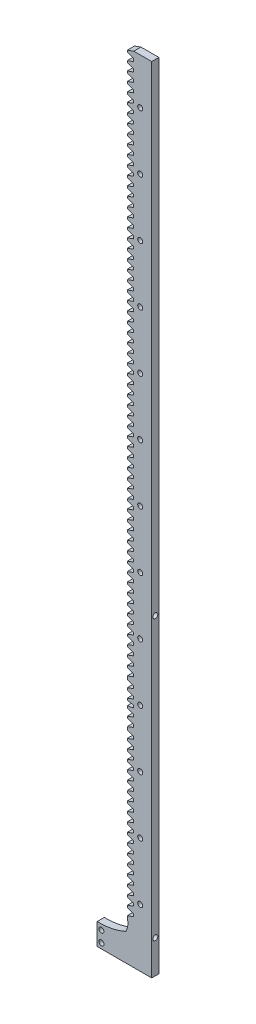
from build123d import *

# Parameters (mm, degrees)
EXTRUDE_1_DEPTH     = 5
SKETCH_2_R          = 1.75
CUT_EXTRUDE_1_DEPTH = 5
SKETCH_3_R          = 1.75
CUT_EXTRUDE_2_DEPTH = 10
SKETCH_4_R          = 1.75
CUT_EXTRUDE_3_DEPTH = 10


with BuildPart() as part:
    # 草图1 → 凸台-拉伸1 (new body)
    with BuildSketch(Plane.XY):
        with BuildLine():
            Line((0, 0), (-38, 0))
            Line((-38, 0), (-38, 15))
            ThreePointArc((-38, 15), (-27.771940478, 15.885441853), (-18.0028, 19.041563393))
            ThreePointArc((-18.0028, 19.041563393), (-16.669513035, 23.308519385), (-17, 27.766696808))
            Line((-17, 27.766696808), (-17, 29.050408521))
            Line((-17, 29.050408521), (-12.5, 30.688274575))
            Line((-12.5, 30.688274575), (-12.5, 32.412016054))
            Line((-12.5, 32.412016054), (-17, 34.049882108))
            Line((-17, 34.049882108), (-17, 35.333593821))
            Line((-17, 35.333593821), (-12.5, 36.971459875))
            Line((-12.5, 36.971459875), (-12.5, 38.695201354))
            Line((-12.5, 38.695201354), (-17, 40.333067408))
            Line((-17, 40.333067408), (-17, 41.616779121))
            Line((-17, 41.616779121), (-12.5, 43.254645175))
            Line((-12.5, 43.254645175), (-12.5, 44.978386654))
            Line((-12.5, 44.978386654), (-17, 46.616252708))
            Line((-17, 46.616252708), (-17, 47.899964421))
            Line((-17, 47.899964421), (-12.5, 49.537830475))
            Line((-12.5, 49.537830475), (-12.5, 51.261571954))
            Line((-12.5, 51.261571954), (-17, 52.899438008))
            Line((-17, 52.899438008), (-17, 54.183149721))
            Line((-17, 54.183149721), (-12.5, 55.821015775))
            Line((-12.5, 55.821015775), (-12.5, 57.544757254))
            Line((-12.5, 57.544757254), (-17, 59.182623308))
            Line((-17, 59.182623308), (-17, 60.466335021))
            Line((-17, 60.466335021), (-12.5, 62.104201075))
            Line((-12.5, 62.104201075), (-12.5, 63.827942554))
            Line((-12.5, 63.827942554), (-17, 65.465808608))
            Line((-17, 65.465808608), (-17, 66.749520321))
            Line((-17, 66.749520321), (-12.5, 68.387386375))
            Line((-12.5, 68.387386375), (-12.5, 70.111127854))
            Line((-12.5, 70.111127854), (-17, 71.748993908))
            Line((-17, 71.748993908), (-17, 73.032705621))
            Line((-17, 73.032705621), (-12.5, 74.670571675))
            Line((-12.5, 74.670571675), (-12.5, 76.394313154))
            Line((-12.5, 76.394313154), (-17, 78.032179208))
            Line((-17, 78.032179208), (-17, 79.315890921))
            Line((-17, 79.315890921), (-12.5, 80.953756975))
            Line((-12.5, 80.953756975), (-12.5, 82.677498454))
            Line((-12.5, 82.677498454), (-17, 84.315364508))
            Line((-17, 84.315364508), (-17, 85.599076221))
            Line((-17, 85.599076221), (-12.5, 87.236942275))
            Line((-12.5, 87.236942275), (-12.5, 88.960683754))
            Line((-12.5, 88.960683754), (-17, 90.598549808))
            Line((-17, 90.598549808), (-17, 91.882261521))
            Line((-17, 91.882261521), (-12.5, 93.520127575))
            Line((-12.5, 93.520127575), (-12.5, 95.243869054))
            Line((-12.5, 95.243869054), (-17, 96.881735108))
            Line((-17, 96.881735108), (-17, 98.165446821))
            Line((-17, 98.165446821), (-12.5, 99.803312875))
            Line((-12.5, 99.803312875), (-12.5, 101.527054354))
            Line((-12.5, 101.527054354), (-17, 103.164920408))
            Line((-17, 103.164920408), (-17, 104.448632121))
            Line((-17, 104.448632121), (-12.5, 106.086498175))
            Line((-12.5, 106.086498175), (-12.5, 107.810239654))
            Line((-12.5, 107.810239654), (-17, 109.448105708))
            Line((-17, 109.448105708), (-17, 110.731817421))
            Line((-17, 110.731817421), (-12.5, 112.369683475))
            Line((-12.5, 112.369683475), (-12.5, 114.093424954))
            Line((-12.5, 114.093424954), (-17, 115.731291008))
            Line((-17, 115.731291008), (-17, 117.015002721))
            Line((-17, 117.015002721), (-12.5, 118.652868775))
            Line((-12.5, 118.652868775), (-12.5, 120.376610254))
            Line((-12.5, 120.376610254), (-17, 122.014476308))
            Line((-17, 122.014476308), (-17, 123.298188021))
            Line((-17, 123.298188021), (-12.5, 124.936054075))
            Line((-12.5, 124.936054075), (-12.5, 126.659795554))
            Line((-12.5, 126.659795554), (-17, 128.297661608))
            Line((-17, 128.297661608), (-17, 129.581373321))
            Line((-17, 129.581373321), (-12.5, 131.219239375))
            Line((-12.5, 131.219239375), (-12.5, 132.942980854))
            Line((-12.5, 132.942980854), (-17, 134.580846908))
            Line((-17, 134.580846908), (-17, 135.864558621))
            Line((-17, 135.864558621), (-12.5, 137.502424675))
            Line((-12.5, 137.502424675), (-12.5, 139.226166154))
            Line((-12.5, 139.226166154), (-17, 140.864032208))
            Line((-17, 140.864032208), (-17, 143.007743921))
            Line((-17, 143.007743921), (-12.5, 144.645609975))
            Line((-12.5, 144.645609975), (-12.5, 146.369351454))
            Line((-12.5, 146.369351454), (-17, 148.007217508))
            Line((-17, 148.007217508), (-17, 149.290929221))
            Line((-17, 149.290929221), (-12.5, 150.928795275))
            Line((-12.5, 150.928795275), (-12.5, 152.652536754))
            Line((-12.5, 152.652536754), (-17, 154.290402808))
            Line((-17, 154.290402808), (-17, 155.574114521))
            Line((-17, 155.574114521), (-12.5, 156.351980575))
            Line((-12.5, 156.351980575), (-12.5, 158.071980575))
            Line((-12.5, 158.071980575), (-17, 158.84984663))
            Line((-17, 158.84984663), (-17, 160.133558343))
            Line((-17, 160.133558343), (-12.5, 161.771424397))
            Line((-12.5, 161.771424397), (-12.5, 163.495165875))
            Line((-12.5, 163.495165875), (-17, 165.13303193))
            Line((-17, 165.13303193), (-17, 166.416743643))
            Line((-17, 166.416743643), (-12.5, 168.054609697))
            Line((-12.5, 168.054609697), (-12.5, 169.778351175))
            Line((-12.5, 169.778351175), (-17, 171.41621723))
            Line((-17, 171.41621723), (-17, 173.559928943))
            Line((-17, 173.559928943), (-12.5, 175.197794997))
            Line((-12.5, 175.197794997), (-12.5, 176.921536475))
            Line((-12.5, 176.921536475), (-17, 178.55940253))
            Line((-17, 178.55940253), (-17, 179.843114243))
            Line((-17, 179.843114243), (-12.5, 181.480980297))
            Line((-12.5, 181.480980297), (-12.5, 183.204721775))
            Line((-12.5, 183.204721775), (-17, 184.84258783))
            Line((-17, 184.84258783), (-17, 186.126299543))
            Line((-17, 186.126299543), (-12.5, 187.764165597))
            Line((-12.5, 187.764165597), (-12.5, 189.487907075))
            Line((-12.5, 189.487907075), (-17, 191.12577313))
            Line((-17, 191.12577313), (-17, 192.409484843))
            Line((-17, 192.409484843), (-12.5, 194.047350897))
            Line((-12.5, 194.047350897), (-12.5, 195.771092375))
            Line((-12.5, 195.771092375), (-17, 197.40895843))
            Line((-17, 197.40895843), (-17, 198.692670143))
            Line((-17, 198.692670143), (-12.5, 200.330536197))
            Line((-12.5, 200.330536197), (-12.5, 202.054277675))
            Line((-12.5, 202.054277675), (-17, 203.69214373))
            Line((-17, 203.69214373), (-17, 204.975855443))
            Line((-17, 204.975855443), (-12.5, 206.613721497))
            Line((-12.5, 206.613721497), (-12.5, 208.337462975))
            Line((-12.5, 208.337462975), (-17, 209.97532903))
            Line((-17, 209.97532903), (-17, 211.259040743))
            Line((-17, 211.259040743), (-12.5, 212.896906797))
            Line((-12.5, 212.896906797), (-12.5, 214.620648275))
            Line((-12.5, 214.620648275), (-17, 216.25851433))
            Line((-17, 216.25851433), (-17, 217.542226043))
            Line((-17, 217.542226043), (-12.5, 219.180092097))
            Line((-12.5, 219.180092097), (-12.5, 220.903833575))
            Line((-12.5, 220.903833575), (-17, 222.54169963))
            Line((-17, 222.54169963), (-17, 223.825411343))
            Line((-17, 223.825411343), (-12.5, 225.463277397))
            Line((-12.5, 225.463277397), (-12.5, 227.187018875))
            Line((-12.5, 227.187018875), (-17, 228.82488493))
            Line((-17, 228.82488493), (-17, 230.108596643))
            Line((-17, 230.108596643), (-12.5, 231.746462697))
            Line((-12.5, 231.746462697), (-12.5, 233.470204175))
            Line((-12.5, 233.470204175), (-17, 235.10807023))
            Line((-17, 235.10807023), (-17, 236.391781943))
            Line((-17, 236.391781943), (-12.5, 238.029647997))
            Line((-12.5, 238.029647997), (-12.5, 239.753389475))
            Line((-12.5, 239.753389475), (-17, 241.39125553))
            Line((-17, 241.39125553), (-17, 242.674967243))
            Line((-17, 242.674967243), (-12.5, 244.312833297))
            Line((-12.5, 244.312833297), (-12.5, 246.036574775))
            Line((-12.5, 246.036574775), (-17, 247.67444083))
            Line((-17, 247.67444083), (-17, 248.958152543))
            Line((-17, 248.958152543), (-12.5, 250.596018597))
            Line((-12.5, 250.596018597), (-12.5, 252.319760075))
            Line((-12.5, 252.319760075), (-17, 253.95762613))
            Line((-17, 253.95762613), (-17, 255.241337843))
            Line((-17, 255.241337843), (-12.5, 256.879203897))
            Line((-12.5, 256.879203897), (-12.5, 258.602945375))
            Line((-12.5, 258.602945375), (-17, 260.24081143))
            Line((-17, 260.24081143), (-17, 261.524523143))
            Line((-17, 261.524523143), (-12.5, 263.162389197))
            Line((-12.5, 263.162389197), (-12.5, 264.886130675))
            Line((-12.5, 264.886130675), (-17, 266.52399673))
            Line((-17, 266.52399673), (-17, 267.807708443))
            Line((-17, 267.807708443), (-12.5, 269.445574497))
            Line((-12.5, 269.445574497), (-12.5, 271.169315975))
            Line((-12.5, 271.169315975), (-17, 272.80718203))
            Line((-17, 272.80718203), (-17, 274.090893743))
            Line((-17, 274.090893743), (-12.5, 275.728759797))
            Line((-12.5, 275.728759797), (-12.5, 277.452501275))
            Line((-12.5, 277.452501275), (-17, 279.09036733))
            Line((-17, 279.09036733), (-17, 280.374079043))
            Line((-17, 280.374079043), (-12.5, 282.011945097))
            Line((-12.5, 282.011945097), (-12.5, 283.735686575))
            Line((-12.5, 283.735686575), (-17, 285.37355263))
            Line((-17, 285.37355263), (-17, 286.657264343))
            Line((-17, 286.657264343), (-12.5, 288.295130397))
            Line((-12.5, 288.295130397), (-12.5, 290.018871875))
            Line((-12.5, 290.018871875), (-17, 291.65673793))
            Line((-17, 291.65673793), (-17, 292.940449643))
            Line((-17, 292.940449643), (-12.5, 294.578315697))
            Line((-12.5, 294.578315697), (-12.5, 296.302057175))
            Line((-12.5, 296.302057175), (-17, 297.93992323))
            Line((-17, 297.93992323), (-17, 299.223634943))
            Line((-17, 299.223634943), (-12.5, 300.861500997))
            Line((-12.5, 300.861500997), (-12.5, 301.721500997))
            Line((-12.5, 301.721500997), (-12.5, 302.581500997))
            Line((-12.5, 302.581500997), (-17, 304.219367051))
            Line((-17, 304.219367051), (-17, 305.503078764))
            Line((-17, 305.503078764), (-12.5, 307.140944818))
            Line((-12.5, 307.140944818), (-12.5, 308.864686297))
            Line((-12.5, 308.864686297), (-17, 310.502552351))
            Line((-17, 310.502552351), (-17, 311.786264064))
            Line((-17, 311.786264064), (-12.5, 313.424130118))
            Line((-12.5, 313.424130118), (-12.5, 315.147871597))
            Line((-12.5, 315.147871597), (-17, 316.785737651))
            Line((-17, 316.785737651), (-17, 318.069449364))
            Line((-17, 318.069449364), (-12.5, 319.707315418))
            Line((-12.5, 319.707315418), (-12.5, 321.431056897))
            Line((-12.5, 321.431056897), (-17, 323.068922951))
            Line((-17, 323.068922951), (-17, 324.352634664))
            Line((-17, 324.352634664), (-12.5, 325.990500718))
            Line((-12.5, 325.990500718), (-12.5, 327.714242197))
            Line((-12.5, 327.714242197), (-17, 329.352108251))
            Line((-17, 329.352108251), (-17, 330.635819964))
            Line((-17, 330.635819964), (-12.5, 332.273686018))
            Line((-12.5, 332.273686018), (-12.5, 333.993686018))
            Line((-12.5, 333.993686018), (-17, 335.631552072))
            Line((-17, 335.631552072), (-17, 336.915263785))
            Line((-17, 336.915263785), (-12.5, 338.553129839))
            Line((-12.5, 338.553129839), (-12.5, 340.273129839))
            Line((-12.5, 340.273129839), (-17, 341.910995894))
            Line((-17, 341.910995894), (-17, 343.194707607))
            Line((-17, 343.194707607), (-12.5, 344.832573661))
            Line((-12.5, 344.832573661), (-12.5, 346.552573661))
            Line((-12.5, 346.552573661), (-17, 348.190439715))
            Line((-17, 348.190439715), (-17, 349.474151428))
            Line((-17, 349.474151428), (-12.5, 351.112017482))
            Line((-12.5, 351.112017482), (-12.5, 352.835758961))
            Line((-12.5, 352.835758961), (-17, 354.473625015))
            Line((-17, 354.473625015), (-17, 355.757336728))
            Line((-17, 355.757336728), (-12.5, 357.395202782))
            Line((-12.5, 357.395202782), (-12.5, 359.118944261))
            Line((-12.5, 359.118944261), (-17, 360.756810315))
            Line((-17, 360.756810315), (-17, 362.040522028))
            Line((-17, 362.040522028), (-12.5, 363.678388082))
            Line((-12.5, 363.678388082), (-12.5, 365.402129561))
            Line((-12.5, 365.402129561), (-17, 367.039995615))
            Line((-17, 367.039995615), (-17, 368.323707328))
            Line((-17, 368.323707328), (-12.5, 369.961573382))
            Line((-12.5, 369.961573382), (-12.5, 371.685314861))
            Line((-12.5, 371.685314861), (-17, 373.323180915))
            Line((-17, 373.323180915), (-17, 374.606892628))
            Line((-17, 374.606892628), (-12.5, 376.244758682))
            Line((-12.5, 376.244758682), (-12.5, 377.104758682))
            Line((-12.5, 377.104758682), (-12.5, 377.964758682))
            Line((-12.5, 377.964758682), (-17, 379.602624736))
            Line((-17, 379.602624736), (-17, 380.886336449))
            Line((-17, 380.886336449), (-12.5, 382.524202503))
            Line((-12.5, 382.524202503), (-12.5, 384.247943982))
            Line((-12.5, 384.247943982), (-17, 385.885810036))
            Line((-17, 385.885810036), (-17, 387.169521749))
            Line((-17, 387.169521749), (-12.5, 388.807387803))
            Line((-12.5, 388.807387803), (-12.5, 390.531129282))
            Line((-12.5, 390.531129282), (-17, 392.168995336))
            Line((-17, 392.168995336), (-17, 393.452707049))
            Line((-17, 393.452707049), (-12.5, 395.090573103))
            Line((-12.5, 395.090573103), (-12.5, 396.814314582))
            Line((-12.5, 396.814314582), (-17, 398.452180636))
            Line((-17, 398.452180636), (-17, 399.735892349))
            Line((-17, 399.735892349), (-12.5, 401.373758403))
            Line((-12.5, 401.373758403), (-12.5, 403.097499882))
            Line((-12.5, 403.097499882), (-17, 404.735365936))
            Line((-17, 404.735365936), (-17, 406.019077649))
            Line((-17, 406.019077649), (-12.5, 407.656943703))
            Line((-12.5, 407.656943703), (-12.5, 409.376943703))
            Line((-12.5, 409.376943703), (-17, 411.014809758))
            Line((-17, 411.014809758), (-17, 412.298521471))
            Line((-17, 412.298521471), (-12.5, 413.936387525))
            Line((-12.5, 413.936387525), (-12.5, 415.660129003))
            Line((-12.5, 415.660129003), (-17, 417.297995058))
            Line((-17, 417.297995058), (-17, 418.581706771))
            Line((-17, 418.581706771), (-12.5, 420.219572825))
            Line((-12.5, 420.219572825), (-12.5, 421.943314303))
            Line((-12.5, 421.943314303), (-17, 423.581180358))
            Line((-17, 423.581180358), (-17, 424.864892071))
            Line((-17, 424.864892071), (-12.5, 426.502758125))
            Line((-12.5, 426.502758125), (-12.5, 428.226499603))
            Line((-12.5, 428.226499603), (-17, 429.864365658))
            Line((-17, 429.864365658), (-17, 431.148077371))
            Line((-17, 431.148077371), (-12.5, 432.785943425))
            Line((-12.5, 432.785943425), (-12.5, 434.509684903))
            Line((-12.5, 434.509684903), (-17, 436.147550958))
            Line((-17, 436.147550958), (-17, 437.431262671))
            Line((-17, 437.431262671), (-12.5, 439.069128725))
            Line((-12.5, 439.069128725), (-12.5, 439.929128725))
            Line((-12.5, 439.929128725), (-12.5, 440.789128725))
            Line((-12.5, 440.789128725), (-17, 442.426994779))
            Line((-17, 442.426994779), (-17, 443.710706492))
            Line((-17, 443.710706492), (-12.5, 445.348572546))
            Line((-12.5, 445.348572546), (-12.5, 447.072314025))
            Line((-12.5, 447.072314025), (-17, 448.710180079))
            Line((-17, 448.710180079), (-17, 449.993891792))
            Line((-17, 449.993891792), (-12.5, 451.631757846))
            Line((-12.5, 451.631757846), (-12.5, 453.355499325))
            Line((-12.5, 453.355499325), (-17, 454.993365379))
            Line((-17, 454.993365379), (-17, 456.277077092))
            Line((-17, 456.277077092), (-12.5, 457.914943146))
            Line((-12.5, 457.914943146), (-12.5, 459.638684625))
            Line((-12.5, 459.638684625), (-17, 461.276550679))
            Line((-17, 461.276550679), (-17, 462.560262392))
            Line((-17, 462.560262392), (-12.5, 464.198128446))
            Line((-12.5, 464.198128446), (-12.5, 465.058128446))
            Line((-12.5, 465.058128446), (-12.5, 465.918128446))
            Line((-12.5, 465.918128446), (-17, 467.5559945))
            Line((-17, 467.5559945), (-17, 468.839706213))
            Line((-17, 468.839706213), (-12.5, 470.477572267))
            Line((-12.5, 470.477572267), (-12.5, 472.201313746))
            Line((-12.5, 472.201313746), (-17, 473.8391798))
            Line((-17, 473.8391798), (-17, 475.122891513))
            Line((-17, 475.122891513), (-12.5, 476.760757567))
            Line((-12.5, 476.760757567), (-12.5, 478.484499046))
            Line((-12.5, 478.484499046), (-17, 480.1223651))
            Line((-17, 480.1223651), (-17, 481.406076813))
            Line((-17, 481.406076813), (-12.5, 483.043942867))
            Line((-12.5, 483.043942867), (-12.5, 484.767684346))
            Line((-12.5, 484.767684346), (-17, 486.4055504))
            Line((-17, 486.4055504), (-17, 487.689262113))
            Line((-17, 487.689262113), (-12.5, 489.327128167))
            Line((-12.5, 489.327128167), (-12.5, 491.050869646))
            Line((-12.5, 491.050869646), (-17, 492.6887357))
            Line((-17, 492.6887357), (-17, 493.972447413))
            Line((-17, 493.972447413), (-12.5, 495.610313467))
            Line((-12.5, 495.610313467), (-12.5, 497.334054946))
            Line((-12.5, 497.334054946), (-17, 498.971921))
            Line((-17, 498.971921), (-17, 500.255632713))
            Line((-17, 500.255632713), (-12.5, 501.893498767))
            Line((-12.5, 501.893498767), (-12.5, 502.753498767))
            Line((-12.5, 502.753498767), (-12.5, 503.613498767))
            Line((-12.5, 503.613498767), (-17, 505.251364822))
            Line((-17, 505.251364822), (-17, 506.535076535))
            Line((-17, 506.535076535), (-12.5, 508.172942589))
            Line((-12.5, 508.172942589), (-12.5, 509.896684067))
            Line((-12.5, 509.896684067), (-17, 511.534550122))
            Line((-17, 511.534550122), (-17, 512.818261835))
            Line((-17, 512.818261835), (-12.5, 514.456127889))
            Line((-12.5, 514.456127889), (-12.5, 516.179869367))
            Line((-12.5, 516.179869367), (-17, 517.817735422))
            Line((-17, 517.817735422), (-17, 519.101447135))
            Line((-17, 519.101447135), (-12.5, 520.739313189))
            Line((-12.5, 520.739313189), (-12.5, 522.463054667))
            Line((-12.5, 522.463054667), (-17, 524.100920722))
            Line((-17, 524.100920722), (-17, 525.384632435))
            Line((-17, 525.384632435), (-12.5, 527.022498489))
            Line((-12.5, 527.022498489), (-12.5, 527.882498489))
            Line((-12.5, 527.882498489), (-12.5, 528.742498489))
            Line((-12.5, 528.742498489), (-17, 530.380364543))
            Line((-17, 530.380364543), (-17, 531.664076256))
            Line((-17, 531.664076256), (-12.5, 533.30194231))
            Line((-12.5, 533.30194231), (-12.5, 535.025683789))
            Line((-12.5, 535.025683789), (-17, 536.663549843))
            Line((-17, 536.663549843), (-17, 537.947261556))
            Line((-17, 537.947261556), (-12.5, 539.58512761))
            Line((-12.5, 539.58512761), (-12.5, 541.308869089))
            Line((-12.5, 541.308869089), (-17, 542.946735143))
            Line((-17, 542.946735143), (-17, 544.230446856))
            Line((-17, 544.230446856), (-12.5, 545.86831291))
            Line((-12.5, 545.86831291), (-12.5, 547.592054389))
            Line((-12.5, 547.592054389), (-17, 549.229920443))
            Line((-17, 549.229920443), (-17, 550.513632156))
            Line((-17, 550.513632156), (-12.5, 552.15149821))
            Line((-12.5, 552.15149821), (0, 552.15149821))
            Line((0, 552.15149821), (0, 345.33321403))
            Line((0, 345.33321403), (0, 332.273686018))
            Line((0, 332.273686018), (0, 300))
            Line((0, 300), (0, 0))
        make_face()
    extrude(amount=EXTRUDE_1_DEPTH)

    # 草图2 → 切除-拉伸1 (cut)
    with BuildSketch(Plane.XY.offset(5)):
        with Locations((-35, 11.338545784)):
            Circle(SKETCH_2_R)
        with Locations((-35, 3.661454216)):
            Circle(SKETCH_2_R)
        with Locations((15, 11)):
            Circle(SKETCH_2_R)
    extrude(amount=-CUT_EXTRUDE_1_DEPTH, mode=Mode.SUBTRACT)

    # 草图3 → 切除-拉伸2 (cut)
    with BuildSketch(Plane(origin=(0, 0, 0), x_dir=(0, 0, -1), z_dir=(1, 0, 0))):
        with Locations((-2.5, 23)):
            Circle(SKETCH_3_R)
        with Locations((-2.5, 217)):
            Circle(SKETCH_3_R)
    extrude(amount=-CUT_EXTRUDE_2_DEPTH, mode=Mode.SUBTRACT)

    # 草图4 → 切除-拉伸3 (cut)
    with BuildSketch(Plane.XY.offset(5)):
        with Locations((-8, 320.33321403)):
            Circle(SKETCH_4_R)
        with Locations((-8, 280.33321403)):
            Circle(SKETCH_4_R)
        with Locations((-8, 240.33321403)):
            Circle(SKETCH_4_R)
        with Locations((-8, 200.33321403)):
            Circle(SKETCH_4_R)
        with Locations((-8, 160.33321403)):
            Circle(SKETCH_4_R)
        with Locations((-8, 120.33321403)):
            Circle(SKETCH_4_R)
        with Locations((-8, 80.33321403)):
            Circle(SKETCH_4_R)
        with Locations((-8, 40.33321403)):
            Circle(SKETCH_4_R)
        with Locations((-8, 360.33321403)):
            Circle(SKETCH_4_R)
        with Locations((-8, 400.33321403)):
            Circle(SKETCH_4_R)
        with Locations((-8, 440.33321403)):
            Circle(SKETCH_4_R)
        with Locations((-8, 480.33321403)):
            Circle(SKETCH_4_R)
        with Locations((-8, 520.33321403)):
            Circle(SKETCH_4_R)
    extrude(amount=-CUT_EXTRUDE_3_DEPTH, mode=Mode.SUBTRACT)


solid = part.part
